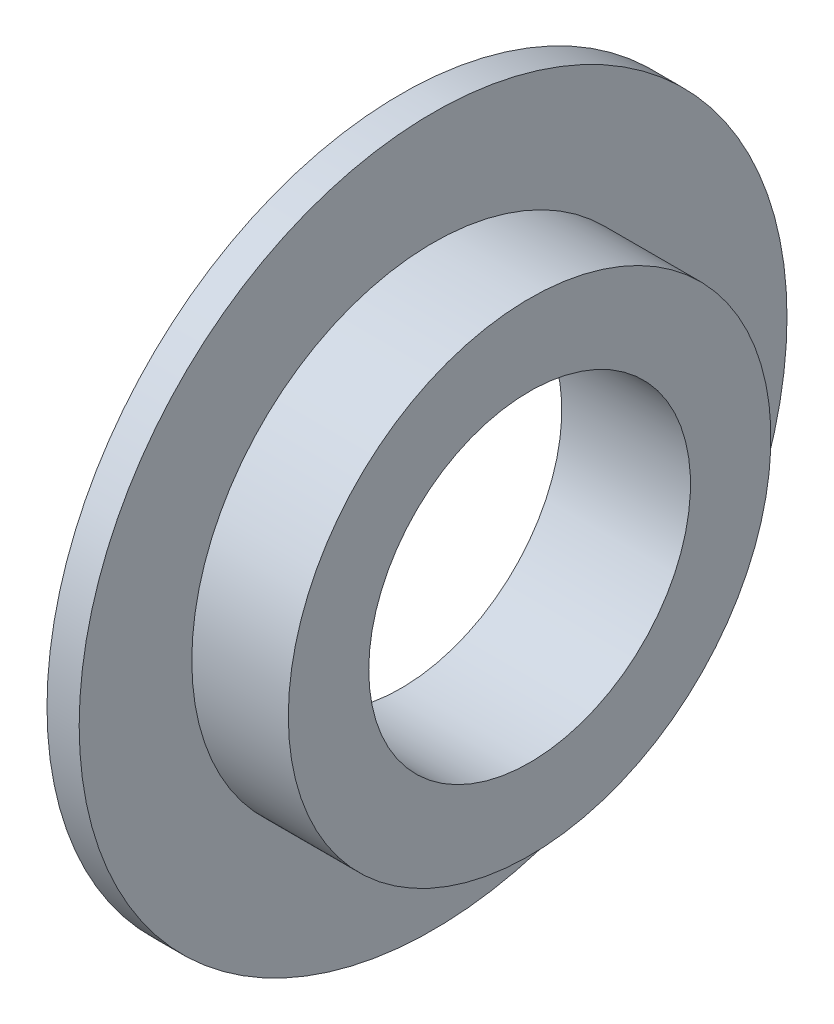
from build123d import *

# Parameters (mm, degrees)
ESQUISSE1_W   = 4
ESQUISSE1_H   = 2.5
ESQUISSE1_W_2 = 1
ESQUISSE1_H_2 = 3.5


with BuildPart() as part:
    # Esquisse1 → Révolution1 (revolve)
    with BuildSketch(Plane.XY):
        with Locations((2, 6.25)):
            Rectangle(ESQUISSE1_W, ESQUISSE1_H)
        with Locations((0.5, 9.25)):
            Rectangle(ESQUISSE1_W_2, ESQUISSE1_H_2)
    revolve(axis=Axis((-7.629438572, 0, 0), (1, 0, 0)))


solid = part.part
